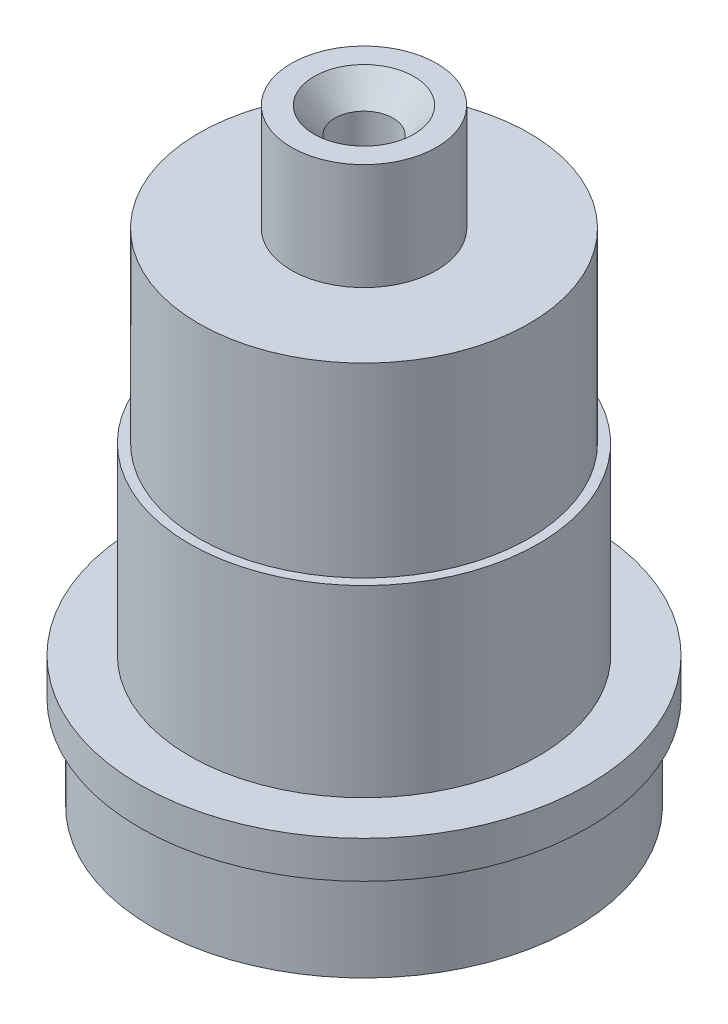
from build123d import *

# Parameters (mm, degrees)
SKETCH1_R           = 23.0505
BOSS_EXTRUDE1_DEPTH = 10.16
SKETCH2_R           = 24.4856
BOSS_EXTRUDE2_DEPTH = 4.064
SKETCH3_R           = 19.05
BOSS_EXTRUDE3_DEPTH = 20.066
SKETCH4_R           = 18.034
BOSS_EXTRUDE4_DEPTH = 20.32
SKETCH5_R           = 7.9375
BOSS_EXTRUDE5_DEPTH = 11.6332
SKETCH7_R           = 3.175
CUT_EXTRUDE1_DEPTH  = 17.018
CHAMFER1_SIZE       = 2.286
CHAMFER1_SIZE2      = 2.794


with BuildPart() as part:
    # Sketch1 → Boss-Extrude1 (new body)
    with BuildSketch(Plane(origin=(0, 0, 0), x_dir=(1, 0, 0), z_dir=(0, 1, 0))):
        Circle(SKETCH1_R)
    extrude(amount=BOSS_EXTRUDE1_DEPTH)

    # Sketch2 → Boss-Extrude2 (add)
    with BuildSketch(Plane(origin=(0, 10.16, 0), x_dir=(1, 0, 0), z_dir=(0, 1, 0))):
        Circle(SKETCH2_R)
    extrude(amount=BOSS_EXTRUDE2_DEPTH)

    # Sketch3 → Boss-Extrude3 (add)
    with BuildSketch(Plane(origin=(0, 14.224, 0), x_dir=(1, 0, 0), z_dir=(0, 1, 0))):
        Circle(SKETCH3_R)
    extrude(amount=BOSS_EXTRUDE3_DEPTH)

    # Sketch4 → Boss-Extrude4 (add)
    with BuildSketch(Plane(origin=(0, 34.29, 0), x_dir=(1, 0, 0), z_dir=(0, 1, 0))):
        Circle(SKETCH4_R)
    extrude(amount=BOSS_EXTRUDE4_DEPTH)

    # Sketch5 → Boss-Extrude5 (add)
    with BuildSketch(Plane(origin=(0, 54.61, 0), x_dir=(1, 0, 0), z_dir=(0, 1, 0))):
        Circle(SKETCH5_R)
    extrude(amount=BOSS_EXTRUDE5_DEPTH)

    # Sketch7 → Cut-Extrude1 (cut)
    with BuildSketch(Plane(origin=(0, 66.2432, 0), x_dir=(1, 0, 0), z_dir=(0, 1, 0))):
        Circle(SKETCH7_R)
    extrude(amount=-CUT_EXTRUDE1_DEPTH, mode=Mode.SUBTRACT)

    # Chamfer1
    chamfer1_edges = [part.edges().sort_by_distance(p)[0] for p in [
        (-3.175, 66.2432, 0),
    ]]
    chamfer1_side = [part.faces().sort_by_distance(p)[0] for p in [
        (-7.712993597, 66.2432, 0),
    ]]
    chamfer(chamfer1_edges, length=CHAMFER1_SIZE, length2=CHAMFER1_SIZE2, reference=chamfer1_side[0])


solid = part.part
